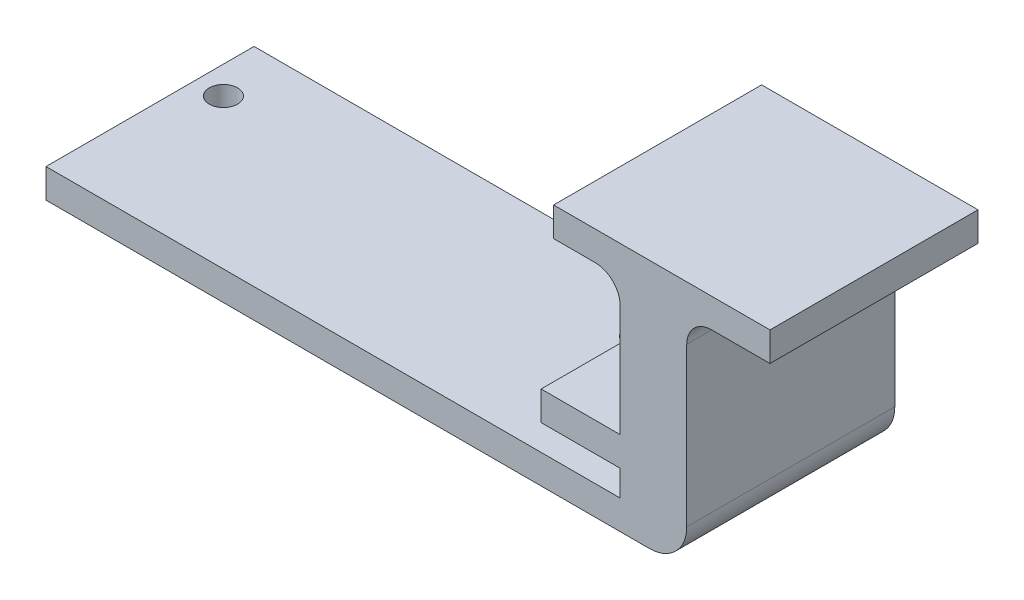
from build123d import *

# Parameters (mm, degrees)
SCHIZZO1_W                        = 77
SCHIZZO1_H                        = 3.5
ESTRUSIONE_ESTRUSIONE1_DEPTH      = 25
SCHIZZO2_W                        = 8
SCHIZZO2_H                        = 25
ESTRUSIONE_ESTRUSIONE2_DEPTH      = 23
SCHIZZO3_W                        = 25
SCHIZZO3_H                        = 3.5
ESTRUSIONE_ESTRUSIONE3_DEPTH      = 9.5
SCHIZZO4_W                        = 25
SCHIZZO4_H                        = 3.5
ESTRUSIONE_ESTRUSIONE4_DEPTH      = 10
ESTRUSIONE_ESTRUSIONE4_DEPTH_BACK = 16
SCHIZZO5_R                        = 1.7
TAGLIO_ESTRUSIONE1_DEPTH          = 8
RACCORDO2_R                       = 4.5
RACCORDO3_R                       = 3
RACCORDO5_R                       = 3


with BuildPart() as part:
    # Schizzo1 → Estrusione-Estrusione1 (new body)
    with BuildSketch(Plane.XY):
        with Locations((31.5, -6.45807022)):
            Rectangle(SCHIZZO1_W, SCHIZZO1_H)
    extrude(amount=ESTRUSIONE_ESTRUSIONE1_DEPTH)

    # Schizzo2 → Estrusione-Estrusione2 (add)
    with BuildSketch(Plane(origin=(0, -4.70807022, 0), x_dir=(1, 0, 0), z_dir=(0, 1, 0))):
        with Locations((66, -12.5)):
            Rectangle(SCHIZZO2_W, SCHIZZO2_H)
    extrude(amount=ESTRUSIONE_ESTRUSIONE2_DEPTH)

    # Schizzo3 → Estrusione-Estrusione3 (add)
    with BuildSketch(Plane.ZY.offset(-62)):
        with Locations((12.5, 0.14192978)):
            Rectangle(SCHIZZO3_W, SCHIZZO3_H)
    extrude(amount=ESTRUSIONE_ESTRUSIONE3_DEPTH)

    # Schizzo4 → Estrusione-Estrusione4 (add, two sides)
    with BuildSketch(Plane(origin=(70, 0, 0), x_dir=(0, 0, -1), z_dir=(1, 0, 0))) as estrusione_estrusione4_sk:
        with Locations((-12.5, 20.04192978)):
            Rectangle(SCHIZZO4_W, SCHIZZO4_H)
    extrude(amount=ESTRUSIONE_ESTRUSIONE4_DEPTH)
    extrude(estrusione_estrusione4_sk.sketch, amount=-ESTRUSIONE_ESTRUSIONE4_DEPTH_BACK)

    # Schizzo5 → Taglio-Estrusione1 (cut)
    with BuildSketch(Plane(origin=(0, -4.70807022, 0), x_dir=(1, 0, 0), z_dir=(0, 1, 0))):
        with Locations((46.319751134, -7)):
            Circle(SCHIZZO5_R)
        with Locations((-3.680248866, -7)):
            Circle(SCHIZZO5_R)
    extrude(amount=-TAGLIO_ESTRUSIONE1_DEPTH, mode=Mode.SUBTRACT)

    # Raccordo2
    raccordo2_edges = [part.edges().sort_by_distance(p)[0] for p in [
        (70, -8.20807022, 12.5),
    ]]
    fillet(raccordo2_edges, radius=RACCORDO2_R)

    # Raccordo3
    raccordo3_edges = [part.edges().sort_by_distance(p)[0] for p in [
        (70, 18.29192978, 12.5),
    ]]
    fillet(raccordo3_edges, radius=RACCORDO3_R)

    # Raccordo5
    raccordo5_edges = [part.edges().sort_by_distance(p)[0] for p in [
        (62, 18.29192978, 12.5),
    ]]
    fillet(raccordo5_edges, radius=RACCORDO5_R)


solid = part.part
